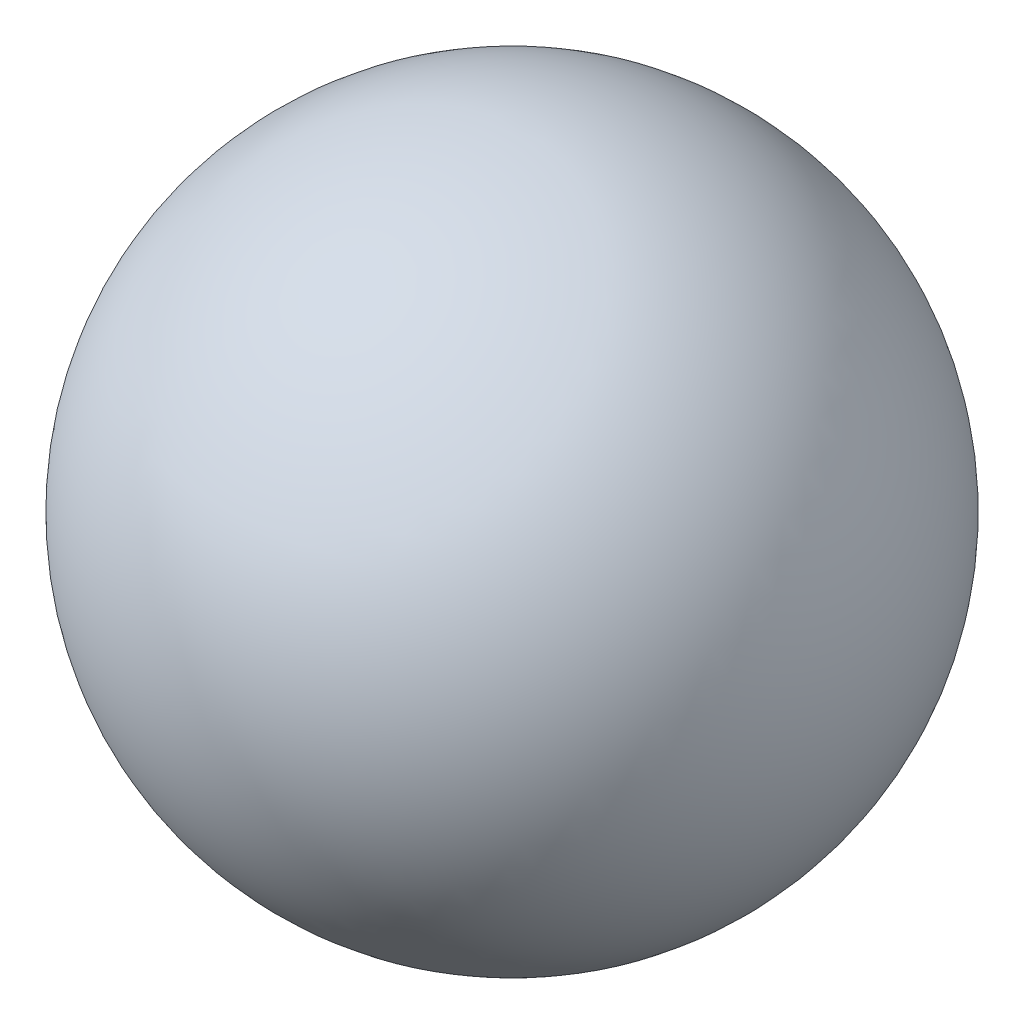
from build123d import *


with BuildPart() as part:
    # Sketch1 → Revolve1 (revolve)
    with BuildSketch(Plane.XY):
        with BuildLine():
            Line((0, 9.5), (0, -9.5))
            ThreePointArc((0, -9.5), (9.5, 0), (0, 9.5))
        make_face()
    revolve(axis=Axis((0, 9.5, 0), (0, -1, 0)))


solid = part.part
